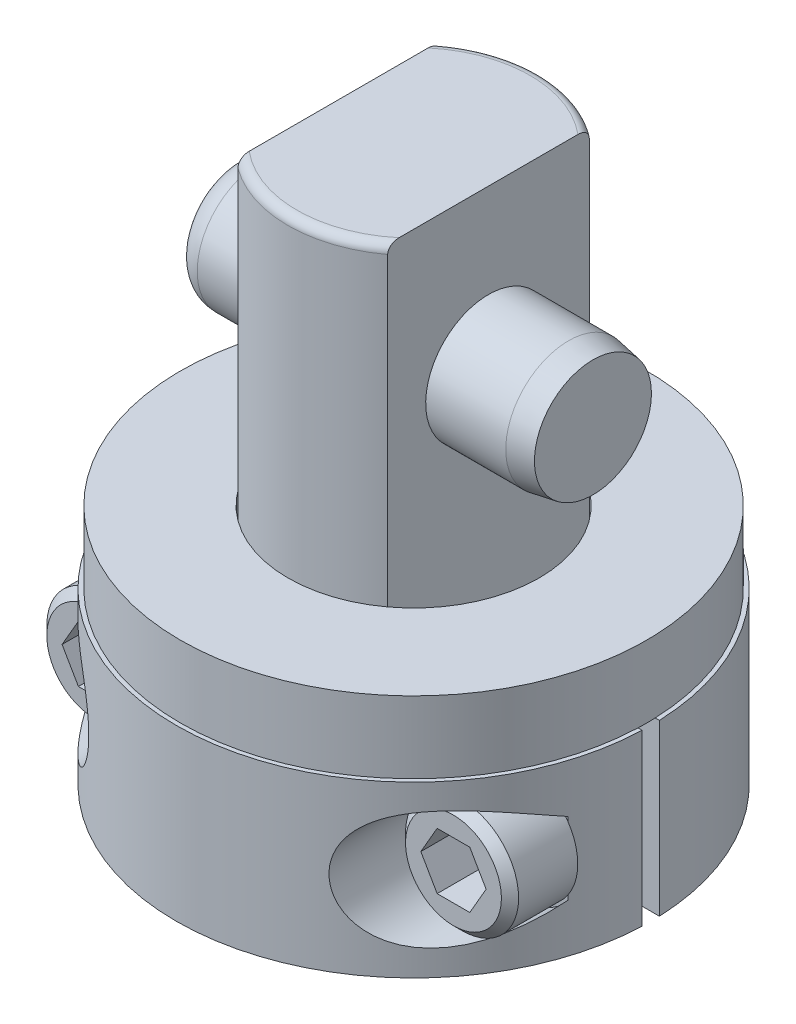
from build123d import *

# Parameters (mm, degrees)
FILLET1_R                  = 0.7874
SKETCH2_W                  = 4.4831
SKETCH2_H                  = 32.8676
CUT_EXTRUDE1_DEPTH         = 12.1125
CUT_EXTRUDE1_DEPTH_BACK    = 12.1125
SKETCH3_R                  = 5.9944
SKETCH3_R_2                = 4.8895
CUT_EXTRUDE2_DEPTH         = 2.54
CHAMFER1_SIZE              = 0.762
SKETCH4_R                  = 5.55879
EXTRUDE1_DEPTH             = 15.875
CHAMFER2_SIZE              = 0.381
CHAMFER2_SIZE2             = 2.160758373
FILLET2_R                  = 2.286
EXTRUDE2_DEPTH             = 7.5057
EXTRUDE2_DEPTH_BACK        = 7.5057
CUT_EXTRUDE3_START         = 5.588
SKETCH6_R                  = 5.2451
CUT_EXTRUDE3_DEPTH         = 15.6558
SKETCH7_R                  = 5.0038
EXTRUDE3_DEPTH             = 5.9944
CHAMFER3_SIZE              = 0.762
CUT_EXTRUDE4_DEPTH         = 5.0038
EXTRUDE4_REACH             = 23.006
SKETCH10_R                 = 2.9972
EXTRUDE4_DIRECTION_2_REACH = 23.006
SKETCH11_R                 = 20.6375
SKETCH11_R_2               = 11.1125
EXTRUDE5_DEPTH             = 6.35


with BuildPart() as part:
    # Sketch1 → Revolve1 (revolve)
    with BuildSketch(Plane(origin=(0, 0, 0), x_dir=(0, 0, -1), z_dir=(1, 0, 0))):
        Polygon((0, 41.656), (11.1125, 41.656), (11.1125, 1.1684), (5.9944, 1.1684), (5.9944, -11.5316), (0, -11.5316), align=None)
    revolve(axis=Axis((0, -15.35938, 0), (0, 1, 0)))

    # Fillet1
    fillet1_edges = [part.edges().sort_by_distance(p)[0] for p in [
        (0, 41.656, 11.1125),
    ]]
    fillet(fillet1_edges, radius=FILLET1_R)

    # Sketch2 → Cut-Extrude1 (cut, two sides)
    with BuildSketch(Plane.XY) as cut_extrude1_sk:
        with Locations((8.87095, 25.2222)):
            Rectangle(SKETCH2_W, SKETCH2_H)
        with Locations((-8.87095, 25.2222)):
            Rectangle(SKETCH2_W, SKETCH2_H)
    extrude(amount=CUT_EXTRUDE1_DEPTH, mode=Mode.SUBTRACT)
    extrude(cut_extrude1_sk.sketch, amount=-CUT_EXTRUDE1_DEPTH_BACK, mode=Mode.SUBTRACT)

    # Sketch3 → Cut-Extrude2 (cut)
    with BuildSketch(Plane.XZ.offset(-1.1684)):
        with Locations(Location((0, 0, 0), (0, 0, 270))):  # turned: the seam where the file's is
            Circle(SKETCH3_R)
        with Locations(Location((0, 0, 0), (0, 0, 270))):  # turned: the seam where the file's is
            Circle(SKETCH3_R_2, mode=Mode.SUBTRACT)
    extrude(amount=CUT_EXTRUDE2_DEPTH, mode=Mode.SUBTRACT)

    # Chamfer1
    chamfer1_edges = [part.edges().sort_by_distance(p)[0] for p in [
        (0, -11.5316, 5.9944),
    ]]
    chamfer(chamfer1_edges, length=CHAMFER1_SIZE)

    # Sketch4 → Extrude1 (add, symmetric)
    with BuildSketch(Plane(origin=(0, 0, 0), x_dir=(0, 0, -1), z_dir=(1, 0, 0))):
        with Locations(Location((0, 27.7876, 0), (0, 0, 90))):  # turned: the seam where the file's is
            Circle(SKETCH4_R)
    extrude(amount=EXTRUDE1_DEPTH, both=True)

    # Chamfer2
    chamfer2_edges = [part.edges().sort_by_distance(p)[0] for p in [
        (15.875, 22.22881, 0),
    ]]
    chamfer2_side = [part.faces().sort_by_distance(p)[0] for p in [
        (15.875, 27.7876, 0),
    ]]
    chamfer(chamfer2_edges, length=CHAMFER2_SIZE, length2=CHAMFER2_SIZE2, reference=chamfer2_side[0])

    # Fillet2
    fillet2_edges = [part.edges().sort_by_distance(p)[0] for p in [
        (-15.875, 22.22881, 0),
    ]]
    fillet(fillet2_edges, radius=FILLET2_R)

    # Sketch5 → Extrude2 (add, two sides)
    with BuildSketch(Plane(origin=(0, 0, 0), x_dir=(1, 0, 0), z_dir=(0, 1, 0))) as extrude2_sk:
        with BuildLine():
            Line((11.086343502, 0.762), (20.99197441, 0.762))
            ThreePointArc((20.99197441, 0.762), (0, 21.0058), (-20.99197441, 0.762))
            Line((-20.99197441, 0.762), (-11.086343502, 0.762))
            ThreePointArc((-11.086343502, 0.762), (0, 11.1125), (11.086343502, 0.762))
        make_face()
        with BuildLine():
            Line((11.086343502, -0.762), (20.99197441, -0.762))
            ThreePointArc((20.99197441, -0.762), (0, -21.0058), (-20.99197441, -0.762))
            Line((-20.99197441, -0.762), (-11.086343502, -0.762))
            ThreePointArc((-11.086343502, -0.762), (0, -11.1125), (11.086343502, -0.762))
        make_face()
    extrude(amount=EXTRUDE2_DEPTH)
    extrude(extrude2_sk.sketch, amount=-EXTRUDE2_DEPTH_BACK)

    # Sketch6 → Cut-Extrude3 (cut, through all)
    with BuildSketch(Plane.XY.offset(0.762).offset(CUT_EXTRUDE3_START)):
        with Locations((15.875, 0)):
            Circle(SKETCH6_R)
        with Locations((-15.875, 0)):
            Circle(SKETCH6_R)
    extrude(amount=CUT_EXTRUDE3_DEPTH, mode=Mode.SUBTRACT)

    # Sketch7 → Extrude3 (add)
    with BuildSketch(Plane.XY.offset(6.35)):
        with Locations(Location((15.875, 0, 0), (0, 0, 325.993384386))):  # turned: the seam where the file's is
            Circle(SKETCH7_R)
        with Locations(Location((-15.875, 0, 0), (0, 0, 214.006615614))):  # turned: the seam where the file's is
            Circle(SKETCH7_R)
    extrude(amount=EXTRUDE3_DEPTH)

    # Chamfer3
    chamfer3_edges = [part.edges().sort_by_distance(p)[0] for p in [
        (11.726984901, 2.798568416, 12.3444),
        (-11.726984901, 2.798568416, 12.3444),
    ]]
    chamfer(chamfer3_edges, length=CHAMFER3_SIZE)

    # Sketch8 → Cut-Extrude4 (cut)
    with BuildSketch(Plane.XY.offset(12.3444)):
        Polygon((17.319472638, 2.5019), (18.763945277, 0), (17.319472638, -2.5019), (14.430527362, -2.5019), (12.986054723, 0), (14.430527362, 2.5019), align=None)
        Polygon((-18.763945277, 0), (-17.319472638, -2.5019), (-14.430527362, -2.5019), (-12.986054723, 0), (-14.430527362, 2.5019), (-17.319472638, 2.5019), align=None)
    extrude(amount=-CUT_EXTRUDE4_DEPTH, mode=Mode.SUBTRACT)

    # Sketch10 → Extrude4 (add, up to next)
    with BuildSketch(Plane.XY, mode=Mode.PRIVATE) as extrude4_sk1:
        with Locations((15.875, 0)):
            Circle(SKETCH10_R)
    extrude4_tool1 = extrude(extrude4_sk1.sketch, amount=EXTRUDE4_REACH, mode=Mode.PRIVATE) - part.part
    add(extrude4_tool1.solids().sort_by_distance((15.875, 0, 0))[0])
    # Sketch10 → Extrude4 (add, up to next)
    with BuildSketch(Plane.XY, mode=Mode.PRIVATE) as extrude4_sk2:
        with Locations((-15.875, 0)):
            Circle(SKETCH10_R)
    extrude4_tool2 = extrude(extrude4_sk2.sketch, amount=EXTRUDE4_REACH, mode=Mode.PRIVATE) - part.part
    add(extrude4_tool2.solids().sort_by_distance((-15.875, 0, 0))[0])

    # Sketch10 → Extrude4 direction 2 (add, up to next)
    with BuildSketch(Plane.XY, mode=Mode.PRIVATE) as extrude4_direction_2_sk1:
        with Locations((15.875, 0)):
            Circle(SKETCH10_R)
    extrude4_direction_2_tool1 = extrude(extrude4_direction_2_sk1.sketch, amount=-EXTRUDE4_DIRECTION_2_REACH, mode=Mode.PRIVATE) - part.part
    add(extrude4_direction_2_tool1.solids().sort_by_distance((15.875, 0, 0))[0])
    # Sketch10 → Extrude4 direction 2 (add, up to next)
    with BuildSketch(Plane.XY, mode=Mode.PRIVATE) as extrude4_direction_2_sk2:
        with Locations((-15.875, 0)):
            Circle(SKETCH10_R)
    extrude4_direction_2_tool2 = extrude(extrude4_direction_2_sk2.sketch, amount=-EXTRUDE4_DIRECTION_2_REACH, mode=Mode.PRIVATE) - part.part
    add(extrude4_direction_2_tool2.solids().sort_by_distance((-15.875, 0, 0))[0])

    # Sketch11 → Extrude5 (add)
    with BuildSketch(Plane(origin=(0, 7.5057, 0), x_dir=(-1, 0, 0), z_dir=(0, 1, 0))):
        with Locations(Location((0, 0, 0), (0, 0, 182.116017459))):  # turned: the seam where the file's is
            Circle(SKETCH11_R)
        Circle(SKETCH11_R_2, mode=Mode.SUBTRACT)
    extrude(amount=EXTRUDE5_DEPTH)


solid = part.part
